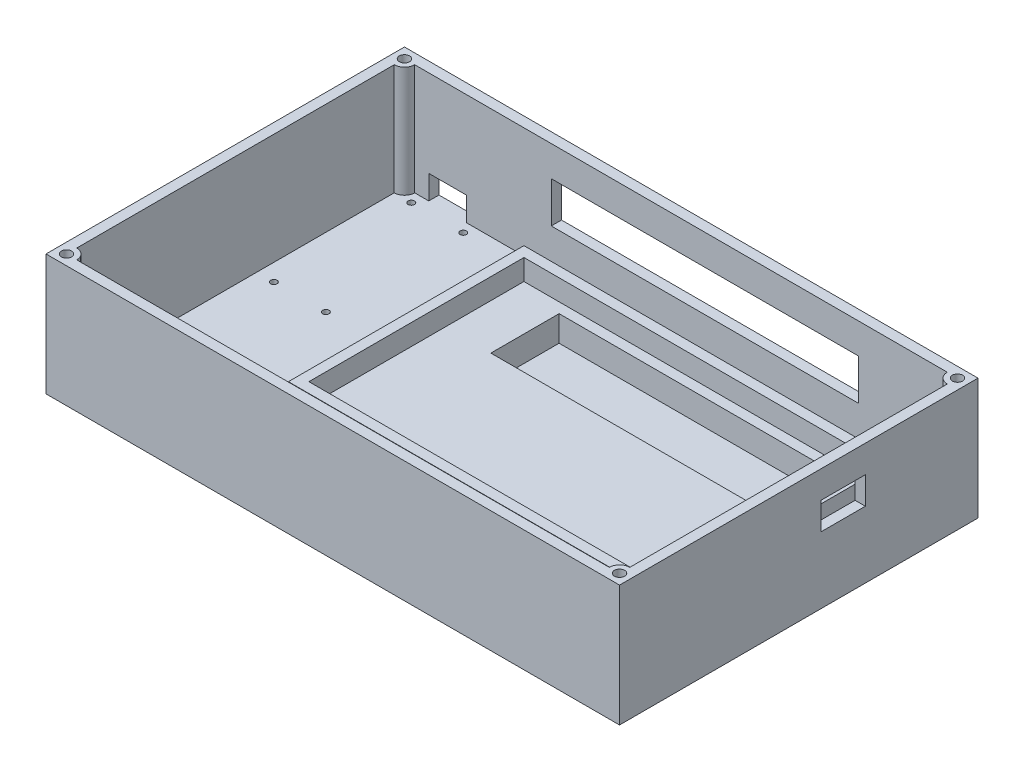
from build123d import *

# Parameters (mm, degrees)
SKETCH1_W           = 168
SKETCH1_H           = 105
BOSS_EXTRUDE1_DEPTH = 35.5
SHELL3_T            = -3
SKETCH3_R           = 0.925
CUT_EXTRUDE2_DEPTH  = 3
SKETCH7_W           = 109
SKETCH7_H           = 69
SKETCH7_W_2         = 103
SKETCH7_H_2         = 63
BOSS_EXTRUDE3_DEPTH = 13.6
SKETCH8_W           = 103
SKETCH8_H           = 63
SKETCH8_W_2         = 75
SKETCH8_H_2         = 20
BOSS_EXTRUDE4_DEPTH = 7.5
SKETCH2_W           = 11
SKETCH2_H           = 7
SKETCH2_W_2         = 90
SKETCH2_H_2         = 12
CUT_EXTRUDE1_DEPTH  = 3
BOSS_EXTRUDE2_DEPTH = 32.5
SKETCH5_R           = 1.5
CUT_EXTRUDE3_DEPTH  = 29.5
SKETCH13_W          = 13
SKETCH13_H          = 8
CUT_EXTRUDE8_DEPTH  = 3


with BuildPart() as part:
    # Sketch1 → Boss-Extrude1 (new body)
    with BuildSketch(Plane(origin=(0, 0, 0), x_dir=(1, 0, 0), z_dir=(0, 1, 0))):
        with Locations((84, 52.5)):
            Rectangle(SKETCH1_W, SKETCH1_H)
    extrude(amount=BOSS_EXTRUDE1_DEPTH)

    # Shell3
    shell3_openings = [part.faces().sort_by_distance(p)[0] for p in [
        (84, 35.5, -52.5),
    ]]
    offset(amount=SHELL3_T, openings=shell3_openings, kind=Kind.INTERSECTION)

    # Sketch3 → Cut-Extrude2 (cut)
    with BuildSketch(Plane(origin=(0, 3, 0), x_dir=(1, 0, 0), z_dir=(0, 1, 0))):
        with Locations((8, 99)):
            Circle(SKETCH3_R)
        with Locations((23.23, 99)):
            Circle(SKETCH3_R)
        with Locations((23.23, 58.76)):
            Circle(SKETCH3_R)
        with Locations((8, 58.76)):
            Circle(SKETCH3_R)
    extrude(amount=-CUT_EXTRUDE2_DEPTH, mode=Mode.SUBTRACT)

    # Sketch7 → Boss-Extrude3 (add)
    with BuildSketch(Plane(origin=(0, 3, 0), x_dir=(1, 0, 0), z_dir=(0, 1, 0))):
        with Locations((103.5, 56.5)):
            Rectangle(SKETCH7_W, SKETCH7_H)
        with Locations((103.5, 56.5)):
            Rectangle(SKETCH7_W_2, SKETCH7_H_2, mode=Mode.SUBTRACT)
    extrude(amount=BOSS_EXTRUDE3_DEPTH)

    # Sketch8 → Boss-Extrude4 (add)
    with BuildSketch(Plane(origin=(0, 3, 0), x_dir=(1, 0, 0), z_dir=(0, 1, 0))):
        with Locations((103.5, 56.5)):
            Rectangle(SKETCH8_W, SKETCH8_H)
        with Locations((102.8, 75)):
            Rectangle(SKETCH8_W_2, SKETCH8_H_2, mode=Mode.SUBTRACT)
    extrude(amount=BOSS_EXTRUDE4_DEPTH)

    # Sketch2 → Cut-Extrude1 (cut)
    with BuildSketch(Plane(origin=(0, 0, -105), x_dir=(-1, 0, 0), z_dir=(0, 0, -1))):
        with Locations((-15.615, 6.5)):
            Rectangle(SKETCH2_W, SKETCH2_H)
        with Locations((-91, 20.6)):
            Rectangle(SKETCH2_W_2, SKETCH2_H_2)
    extrude(amount=-CUT_EXTRUDE1_DEPTH, mode=Mode.SUBTRACT)

    # Sketch4 → Boss-Extrude2 (add)
    with BuildSketch(Plane(origin=(0, 3, 0), x_dir=(1, 0, 0), z_dir=(0, 1, 0))):
        with BuildLine():
            Line((6, 102), (3, 102))
            Line((3, 102), (3, 99))
            ThreePointArc((3, 99), (5.121320344, 99.878679656), (6, 102))
        make_face()
        with BuildLine():
            Line((162, 102), (165, 102))
            Line((165, 102), (165, 99))
            ThreePointArc((165, 99), (162.878679656, 99.878679656), (162, 102))
        make_face()
        with BuildLine():
            Line((165, 3), (165, 6))
            ThreePointArc((165, 6), (162.878679656, 5.121320344), (162, 3))
            Line((162, 3), (165, 3))
        make_face()
        with BuildLine():
            Line((6, 3), (3, 3))
            Line((3, 3), (3, 6))
            ThreePointArc((3, 6), (5.121320344, 5.121320344), (6, 3))
        make_face()
    extrude(amount=BOSS_EXTRUDE2_DEPTH)

    # Sketch5 → Cut-Extrude3 (cut)
    with BuildSketch(Plane(origin=(0, 35.5, 0), x_dir=(1, 0, 0), z_dir=(0, 1, 0))):
        with Locations((3, 102)):
            Circle(SKETCH5_R)
        with Locations((165, 102)):
            Circle(SKETCH5_R)
        with Locations((3, 3)):
            Circle(SKETCH5_R)
        with Locations((165, 3)):
            Circle(SKETCH5_R)
    extrude(amount=-CUT_EXTRUDE3_DEPTH, mode=Mode.SUBTRACT)

    # Sketch13 → Cut-Extrude8 (cut)
    with BuildSketch(Plane(origin=(168, 0, 0), x_dir=(0, 0, -1), z_dir=(1, 0, 0))):
        with Locations((65.5, 23.5)):
            Rectangle(SKETCH13_W, SKETCH13_H)
    extrude(amount=-CUT_EXTRUDE8_DEPTH, mode=Mode.SUBTRACT)


solid = part.part
